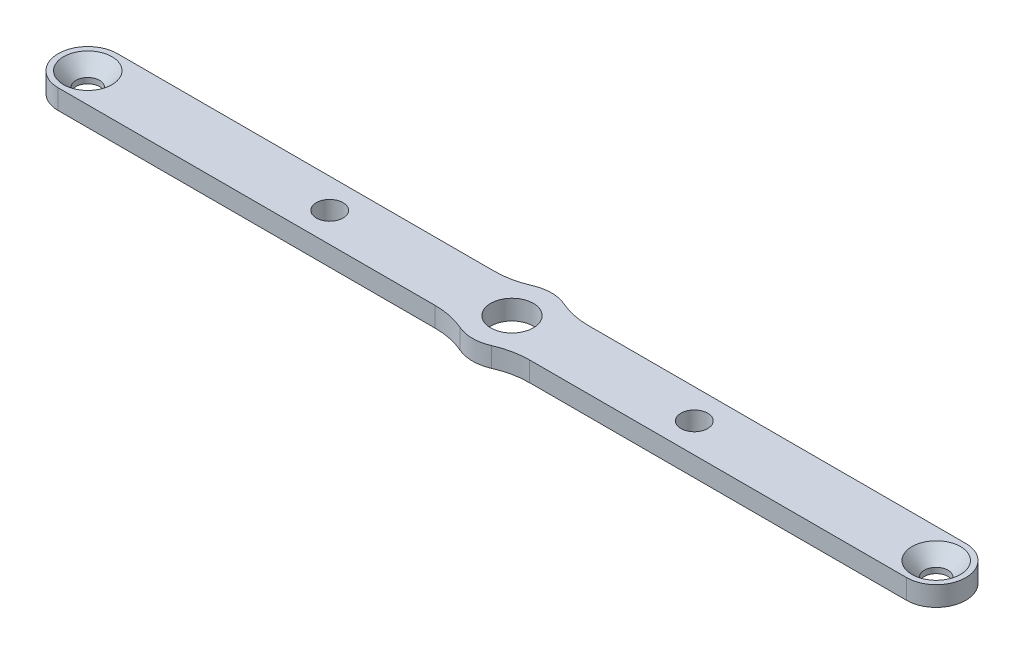
from build123d import *

# Parameters (mm, degrees)
SKETCH1_R           = 1.905
SKETCH1_R_2         = 2.151722897
SKETCH1_R_3         = 3.429
BOSS_EXTRUDE1_DEPTH = 3.175
FILLET1_R           = 12.7


with BuildPart() as part:
    # Sketch1 → Boss-Extrude1 (new body)
    with BuildSketch(Plane(origin=(0, 0, 0), x_dir=(1, 0, 0), z_dir=(0, 1, 0))):
        with BuildLine():
            Line((-4.200130206, 4.7625), (-68.2625, 4.7625))
            ThreePointArc((-68.2625, 4.7625), (-73.025, 0), (-68.2625, -4.7625))
            Line((-68.2625, -4.7625), (-4.200130206, -4.7625))
            ThreePointArc((-4.200130206, -4.7625), (0, -6.35), (4.200130206, -4.7625))
            Line((4.200130206, -4.7625), (68.2625, -4.7625))
            ThreePointArc((68.2625, -4.7625), (73.025, 0), (68.2625, 4.7625))
            Line((68.2625, 4.7625), (4.200130206, 4.7625))
            ThreePointArc((4.200130206, 4.7625), (0, 6.35), (-4.200130206, 4.7625))
        make_face()
        with Locations((-68.2625, 0)):
            Circle(SKETCH1_R, mode=Mode.SUBTRACT)
        with Locations((-29.337, 0)):
            Circle(SKETCH1_R_2, mode=Mode.SUBTRACT)
        Circle(SKETCH1_R_3, mode=Mode.SUBTRACT)
        with Locations((68.2625, 0)):
            Circle(SKETCH1_R, mode=Mode.SUBTRACT)
        with Locations((29.337, 0)):
            Circle(SKETCH1_R_2, mode=Mode.SUBTRACT)
    extrude(amount=BOSS_EXTRUDE1_DEPTH)

    # Fillet1
    fillet1_edges = [part.edges().sort_by_distance(p)[0] for p in [
        (-4.200130206, 1.5875, -4.7625),
        (4.200130206, 1.5875, -4.7625),
        (4.200130206, 1.5875, 4.7625),
        (-4.200130206, 1.5875, 4.7625),
    ]]
    fillet(fillet1_edges, radius=FILLET1_R)

    # Sketch5 → Cut-Revolve2 (revolve, cut)
    with BuildSketch(Plane.XY):
        Polygon((-64.3636, 3.175), (-66.505348665, 0.7112), (-66.505348665, 3.175), align=None)
    cut_revolve2 = revolve(axis=Axis((-68.2625, 0, 0), (0, 1, 0)), mode=Mode.SUBTRACT)

    # Mirror1: Cut-Revolve2 across plane
    add(cut_revolve2.mirror(Plane(origin=(0, 0, 0), x_dir=(0, 0, 1), z_dir=(1, 0, 0))), mode=Mode.SUBTRACT)


solid = part.part
